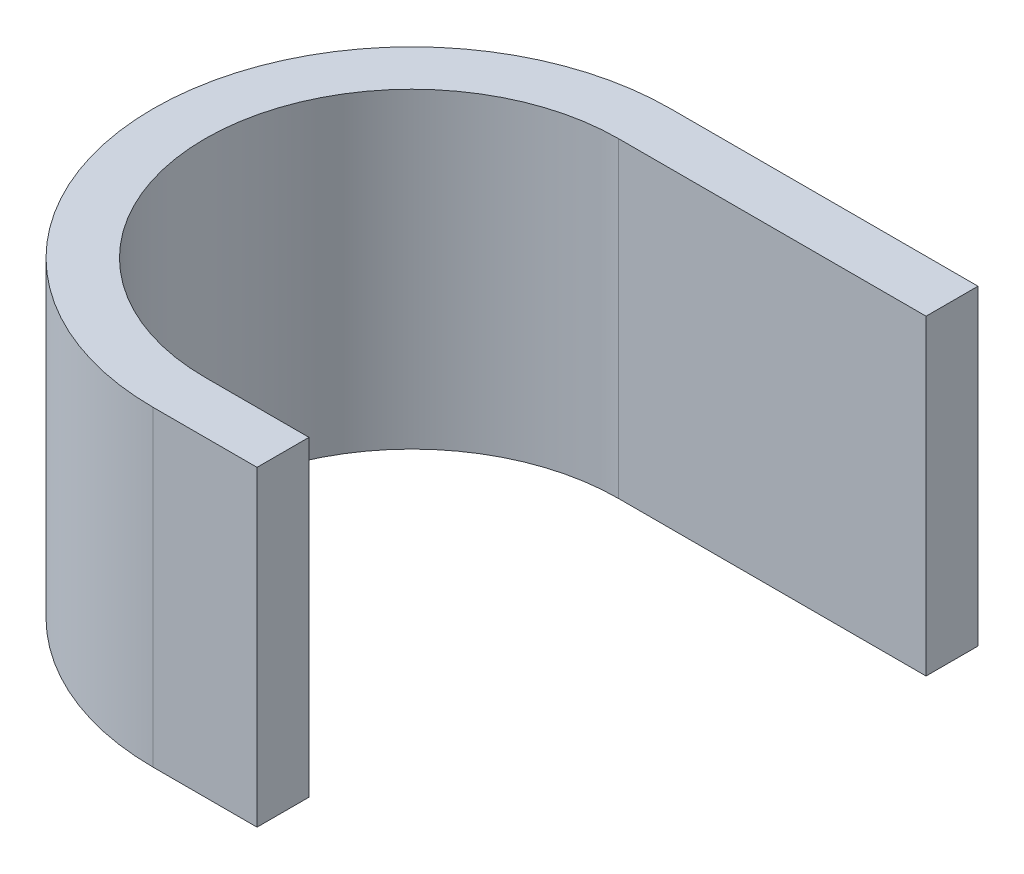
from build123d import *

# Parameters (mm, degrees)
BOSS_EXTRUDE1_DEPTH = 30


with BuildPart() as part:
    # Sketch1 → Boss-Extrude1 (new body)
    with BuildSketch(Plane(origin=(0, 0, 0), x_dir=(1, 0, 0), z_dir=(0, 1, 0))):
        with BuildLine():
            Line((0, 19.9), (29.6, 19.9))
            Line((29.6, 19.9), (29.6, 24.9))
            Line((29.6, 24.9), (0, 24.9))
            ThreePointArc((0, 24.9), (-24.9, 0), (0, -24.9))
            Line((0, -24.9), (10, -24.9))
            Line((10, -24.9), (10, -19.9))
            Line((10, -19.9), (0, -19.9))
            ThreePointArc((0, -19.9), (-19.9, 0), (0, 19.9))
        make_face()
    extrude(amount=BOSS_EXTRUDE1_DEPTH)


solid = part.part
